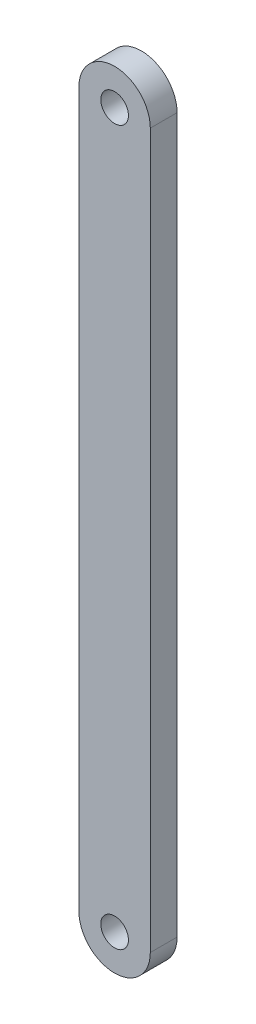
from build123d import *

# Parameters (mm, degrees)
MODEL_R             = 1.550000002
BOSS_EXTRUDE1_DEPTH = 3


with BuildPart() as part:
    # Model → Boss-Extrude1 (new body)
    with BuildSketch(Plane.XY):
        with BuildLine():
            Line((56, 79.999999192), (56, -8.06e-07))
            ThreePointArc((56, -8.06e-07), (59.999999998, -4.000000808), (64, -8.07e-07))
            Line((64, -8.07e-07), (64, 79.999999192))
            ThreePointArc((64, 79.999999192), (59.999999999, 83.999999192), (56, 79.999999192))
        make_face()
        with Locations((59.999999998, 79.999999191)):
            Circle(MODEL_R, mode=Mode.SUBTRACT)
        with Locations((59.999999998, -8.09e-07)):
            Circle(MODEL_R, mode=Mode.SUBTRACT)
    extrude(amount=BOSS_EXTRUDE1_DEPTH)


solid = part.part
